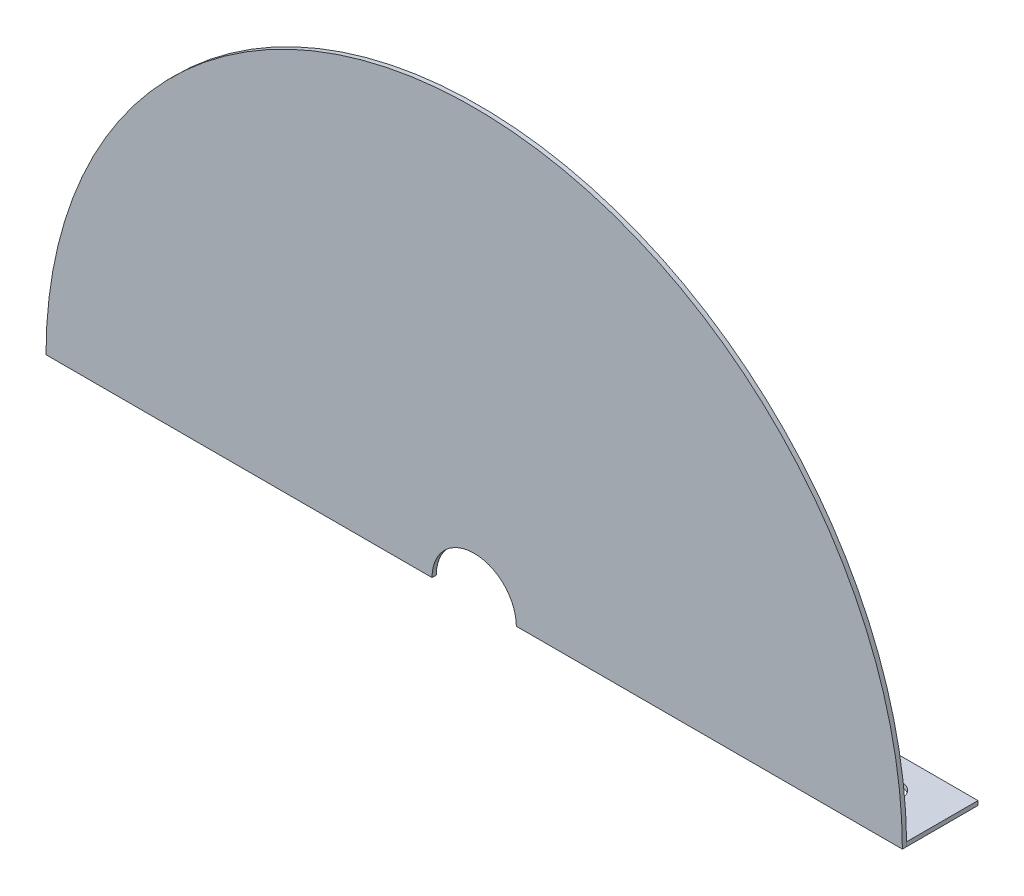
from build123d import *

# Parameters (mm, degrees)
OUTER_CASING_DEPTH  = 1.51892
SKETCH1_R           = 15
INNER_CUTOUT_DEPTH  = 20
SKETCH4_W           = 76.2
SKETCH4_H           = 1.51892
BOSS_EXTRUDE1_DEPTH = 25.4
SKETCH5_R           = 4.7625
CUT_EXTRUDE1_DEPTH  = 2.51892


with BuildPart() as part:
    # Plate shape → Outer casing (new body)
    with BuildSketch(Plane.XY):
        with BuildLine():
            Line((0, 152.4), (-152.4, 152.4))
            ThreePointArc((-152.4, 152.4), (0, 304.8), (152.4, 152.4))
            Line((152.4, 152.4), (0, 152.4))
        make_face()
    extrude(amount=OUTER_CASING_DEPTH)

    # Sketch1 → Inner Cutout (cut)
    with BuildSketch(Plane.XY.offset(1.51892)):
        with Locations((0, 152.4)):
            Circle(SKETCH1_R)
    extrude(amount=-INNER_CUTOUT_DEPTH, mode=Mode.SUBTRACT)

    # Sketch4 → Boss-Extrude1 (add)
    with BuildSketch(Plane(origin=(0, 0, 0), x_dir=(-1, 0, 0), z_dir=(0, 0, -1))):
        with Locations((-114.3, 153.15946)):
            Rectangle(SKETCH4_W, SKETCH4_H)
        with Locations((114.3, 153.15946)):
            Rectangle(SKETCH4_W, SKETCH4_H)
    extrude(amount=BOSS_EXTRUDE1_DEPTH)

    # Sketch5 → Cut-Extrude1 (cut, through all)
    with BuildSketch(Plane(origin=(0, 153.91892, 0), x_dir=(1, 0, 0), z_dir=(0, 1, 0))):
        with Locations((133.35, 12.7)):
            Circle(SKETCH5_R)
        with Locations((95.25, 12.7)):
            Circle(SKETCH5_R)
        with Locations((-133.35, 12.7)):
            Circle(SKETCH5_R)
        with Locations((-95.25, 12.7)):
            Circle(SKETCH5_R)
    extrude(amount=-CUT_EXTRUDE1_DEPTH, mode=Mode.SUBTRACT)


solid = part.part
